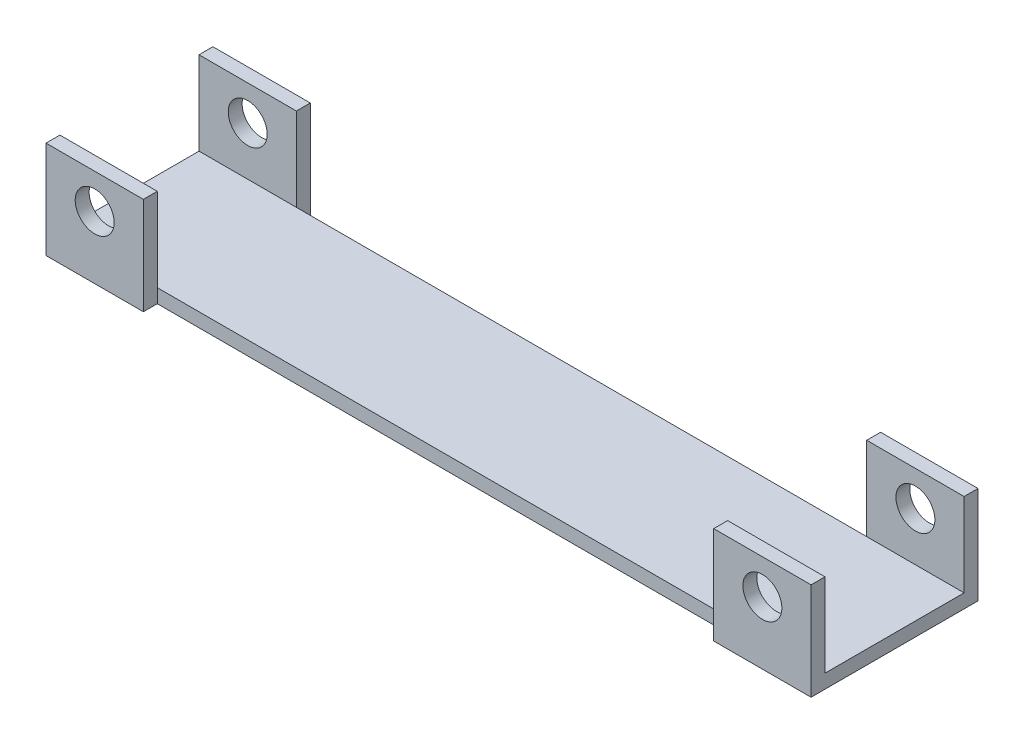
from build123d import *

# Parameters (mm, degrees)
SZKIC1_W                    = 275
SZKIC1_H                    = 50
DODANIE_WYCI_GNI_CIE1_DEPTH = 5
SZKIC2_W                    = 35
SZKIC2_H                    = 35
SZKIC2_R                    = 7
DODANIE_WYCI_GNI_CIE2_DEPTH = 5


with BuildPart() as part:
    # Szkic1 → Dodanie-wyciągnięcie1 (new body)
    with BuildSketch(Plane(origin=(0, 0, 0), x_dir=(1, 0, 0), z_dir=(0, 1, 0))):
        with Locations((137.5, 25)):
            Rectangle(SZKIC1_W, SZKIC1_H)
    extrude(amount=DODANIE_WYCI_GNI_CIE1_DEPTH)

    # Szkic2 → Dodanie-wyciągnięcie2 (add)
    with BuildSketch(Plane.XY):
        with Locations((17.5, 17.5)):
            Rectangle(SZKIC2_W, SZKIC2_H)
        with Locations((17.5, 22.5)):
            Circle(SZKIC2_R, mode=Mode.SUBTRACT)
        with Locations((257.5, 17.5)):
            Rectangle(SZKIC2_W, SZKIC2_H)
        with Locations((257.5, 22.5)):
            Circle(SZKIC2_R, mode=Mode.SUBTRACT)
    dodanie_wyci_gni_cie2 = extrude(amount=DODANIE_WYCI_GNI_CIE2_DEPTH)

    # Lustro1: Dodanie-wyciągnięcie2 across plane
    add(dodanie_wyci_gni_cie2.mirror(Plane(origin=(0, 0, -25), x_dir=(1, 0, 0), z_dir=(0, 0, -1))))


solid = part.part
